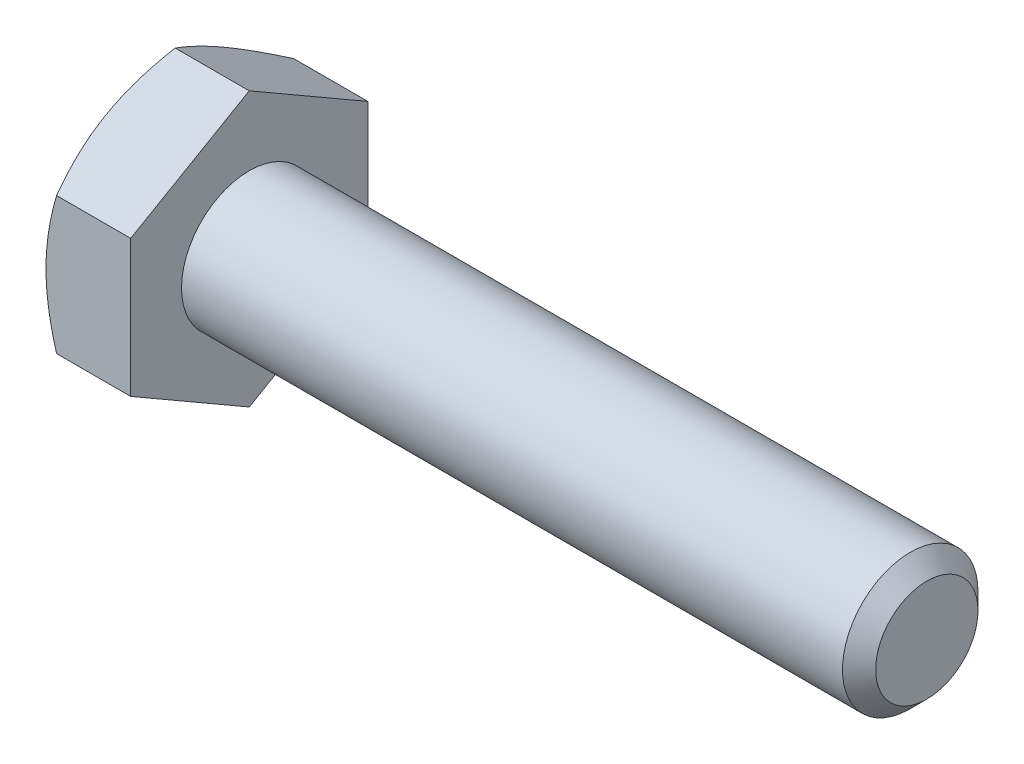
from build123d import *

# Parameters (mm, degrees)
SKETCH5_R           = 3.175
BOSS_EXTRUDE3_DEPTH = 31.75
CHAMFER1_SIZE       = 0.77724
BOSS_EXTRUDE4_DEPTH = 3.96875
SKETCH8_OUTSIDE_W   = 148.218
SKETCH8_OUTSIDE_H   = 149.938
SKETCH8_OUTSIDE_R   = 5.55625
CUT_EXTRUDE3_DEPTH  = 36.71875
CUT_EXTRUDE3_TAPER  = 60
CUT_EXTRUDE4_DEPTH  = 0.254
CIRPATTERN1_COUNT   = 3


with BuildPart() as part:
    # Sketch5 → Boss-Extrude3 (new body)
    with BuildSketch(Plane(origin=(17.859375, 0, 0), x_dir=(0, 0, -1), z_dir=(1, 0, 0))):
        Circle(SKETCH5_R)
    extrude(amount=-BOSS_EXTRUDE3_DEPTH)

    # Chamfer1
    chamfer1_edges = [part.edges().sort_by_distance(p)[0] for p in [
        (17.859375, 0, 3.175),
    ]]
    chamfer(chamfer1_edges, length=CHAMFER1_SIZE)

    # Sketch6 → Boss-Extrude4 (add)
    with BuildSketch(Plane.ZY.offset(13.890625)):
        Polygon((5.55625, 3.207902433), (0, 6.415804866), (-5.55625, 3.207902433), (-5.55625, -3.207902433), (0, -6.415804866), (5.55625, -3.207902433), align=None)
    extrude(amount=BOSS_EXTRUDE4_DEPTH)

    # Sketch8 outside → Cut-Extrude3 (cut, through all)
    with BuildSketch(Plane.ZY.offset(17.859375)):
        Rectangle(SKETCH8_OUTSIDE_W, SKETCH8_OUTSIDE_H)
        Circle(SKETCH8_OUTSIDE_R, mode=Mode.SUBTRACT)
    extrude(amount=-CUT_EXTRUDE3_DEPTH, taper=CUT_EXTRUDE3_TAPER, mode=Mode.SUBTRACT)

    # Sketch12 → Cut-Extrude4 (cut)
    with BuildSketch(Plane.ZY.offset(17.859375)):
        with BuildLine():
            Line((0.1666875, 4.2783125), (0.1666875, 2.3891875))
            ThreePointArc((0.1666875, 2.3891875), (0, 2.2225), (-0.1666875, 2.3891875))
            Line((-0.1666875, 2.3891875), (-0.1666875, 4.2783125))
            ThreePointArc((-0.1666875, 4.2783125), (0, 4.445), (0.1666875, 4.2783125))
        make_face()
    cut_extrude4 = extrude(amount=-CUT_EXTRUDE4_DEPTH, mode=Mode.SUBTRACT)

    # CirPattern1: Cut-Extrude4 ×3 about axis
    cirpattern1_axis = Axis((0, 0, 0), (1, 0, 0))
    for i in range(1, CIRPATTERN1_COUNT):
        add(cut_extrude4.rotate(cirpattern1_axis, i * 360 / CIRPATTERN1_COUNT), mode=Mode.SUBTRACT)


solid = part.part
